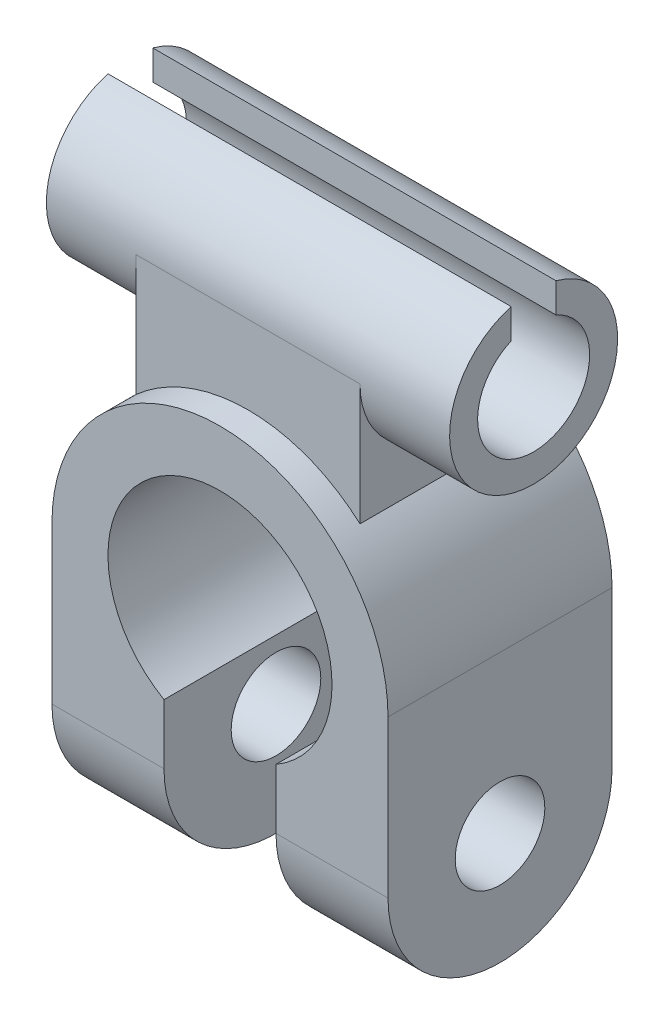
from build123d import *
from build123d.topology import SkipClean

# Parameters (mm, degrees)
BIG_CYL_DEPTH       = 20
HALF_CIRCLE_DEPTH   = 10
SMALL_CYL_DEPTH     = 10
HALF_START          = -10
HALF_CIRCLE_2_DEPTH = 10
SMAL_START          = -10
SMAL_CYL_2_DEPTH    = 10
LONG_CYL_DEPTH      = 18
BASE_DEPTH          = 10


with BuildPart() as part:
    # Sketch1 → big cyl (new body)
    with BuildSketch(Plane.XY):
        with BuildLine():
            Line((-15, 0), (-15, -14))
            Line((-15, -14), (-5, -14))
            Line((-5, -14), (-5, -8.660254038))
            ThreePointArc((-5, -8.660254038), (0, 10), (5, -8.660254038))
            Line((5, -8.660254038), (5, -14))
            Line((5, -14), (15, -14))
            Line((15, -14), (15, 0))
            ThreePointArc((15, 0), (0, 15), (-15, 0))
        make_face()
    extrude(amount=-BIG_CYL_DEPTH)

    # Sketch2 → half circle (add)
    with BuildSketch(Plane.ZY.offset(15)):
        with BuildLine():
            Line((-14, -14), (-20, -14))
            ThreePointArc((-20, -14), (-10, -24), (0, -14))
            Line((0, -14), (-6, -14))
            ThreePointArc((-6, -14), (-10, -18), (-14, -14))
        make_face()
    extrude(amount=-HALF_CIRCLE_DEPTH)

    # Sketch2_5 → small cyl (cut)
    with SkipClean():  # the faces are left unmerged after this step: merging them gives an invalid solid
        with BuildSketch(Plane.ZY.offset(15)):
            with BuildLine():
                Line((-14, -14), (-6, -14))
                ThreePointArc((-6, -14), (-10, -10), (-14, -14))
            make_face()
        extrude(amount=-SMALL_CYL_DEPTH, mode=Mode.SUBTRACT)

    # Sketch4 → half circle 2 (add)
    with SkipClean():  # the faces are left unmerged after this step: merging them gives an invalid solid
        with BuildSketch(Plane(origin=(15, 0, 0), x_dir=(0, 0, -1), z_dir=(1, 0, 0)).offset(HALF_START)):
            with BuildLine():
                Line((6, -14), (0, -14))
                ThreePointArc((0, -14), (10, -24), (20, -14))
                Line((20, -14), (14, -14))
                ThreePointArc((14, -14), (10, -18), (6, -14))
            make_face()
        extrude(amount=HALF_CIRCLE_2_DEPTH)

    # Sketch4_4 → smal cyl 2 (cut)
    with SkipClean():  # the faces are left unmerged after this step: merging them gives an invalid solid
        with BuildSketch(Plane(origin=(15, 0, 0), x_dir=(0, 0, -1), z_dir=(1, 0, 0)).offset(SMAL_START)):
            with BuildLine():
                ThreePointArc((14, -14), (10, -10), (6, -14))
                Line((6, -14), (14, -14))
            make_face()
            with BuildLine():
                Line((14, -14), (6, -14))
                ThreePointArc((6, -14), (10, -18), (14, -14))
            make_face()
        extrude(amount=SMAL_CYL_2_DEPTH, mode=Mode.SUBTRACT)

    # Sketch5 → long cyl (add, symmetric)
    with SkipClean():  # the faces are left unmerged after this step: merging them gives an invalid solid
        with BuildSketch(Plane(origin=(0, 0, 0), x_dir=(0, 0, -1), z_dir=(1, 0, 0))):
            with BuildLine():
                ThreePointArc((8, 29.228416147), (4.031331807, 26.541475531), (2.5, 22))
                ThreePointArc((2.5, 22), (10, 14.5), (17.5, 22))
                ThreePointArc((17.5, 22), (15.968668193, 26.541475531), (12, 29.228416147))
                Line((12, 29.228416147), (12, 26.582575695))
                ThreePointArc((12, 26.582575695), (14.183300133, 24.738612788), (15, 22))
                ThreePointArc((15, 22), (7.261387212, 17.816699867), (8, 26.582575695))
                Line((8, 26.582575695), (8, 29.228416147))
            make_face()
        extrude(amount=LONG_CYL_DEPTH, both=True)

    # Sketch5_3 → base (add, symmetric)
    with SkipClean():  # the faces are left unmerged after this step: merging them gives an invalid solid
        with BuildSketch(Plane(origin=(0, 0, 0), x_dir=(0, 0, -1), z_dir=(1, 0, 0))):
            with BuildLine():
                ThreePointArc((17.5, 22), (10, 14.5), (2.5, 22))
                Line((2.5, 22), (2.5, 10.5))
                Line((2.5, 10.5), (17.5, 10.5))
                Line((17.5, 10.5), (17.5, 22))
            make_face()
        extrude(amount=BASE_DEPTH, both=True)


solid = part.part
